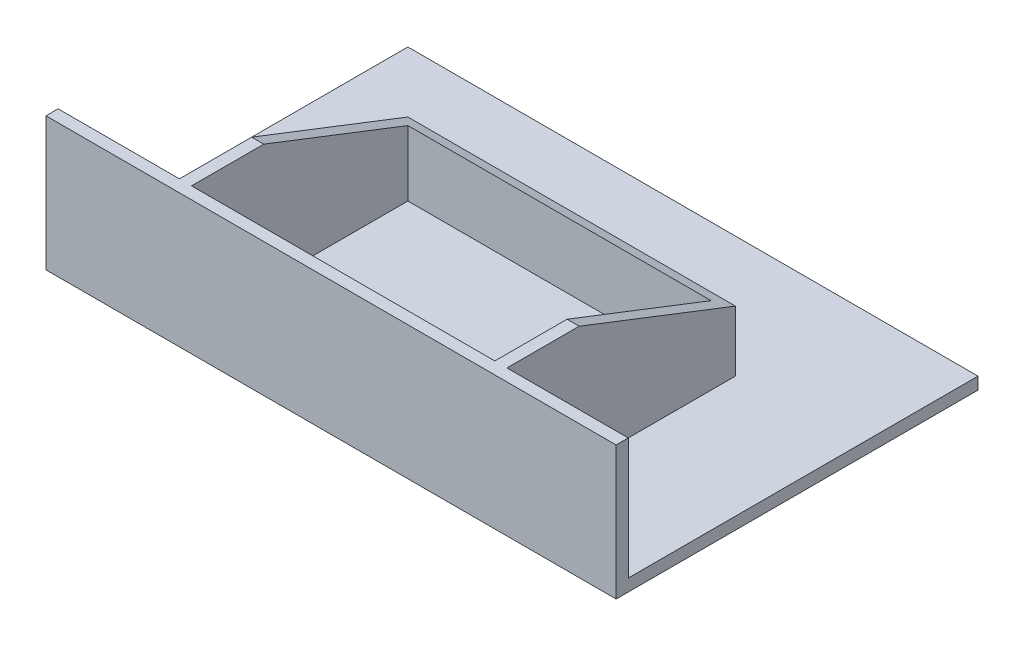
from build123d import *

# Parameters (mm, degrees)
CROQUIS1_R              = 2.1
SALIENTE_EXTRUIR1_DEPTH = 27
CROQUIS2_W              = 50
CROQUIS2_H              = 35.661242199
CORTAR_EXTRUIR1_DEPTH   = 20
CROQUIS3_W              = 94
CROQUIS3_H              = 22
SALIENTE_EXTRUIR2_DEPTH = 2
CROQUIS4_W              = 94
CROQUIS4_H              = 57.661242199
SALIENTE_EXTRUIR3_DEPTH = 2


with BuildPart() as part:
    # Croquis1 → Saliente-Extruir1 (new body, symmetric)
    with BuildSketch(Plane(origin=(0, 0, 0), x_dir=(0, 0, -1), z_dir=(1, 0, 0))):
        Polygon((0, 0), (0, 20), (11.90751736, 20), (37.661242199, 10), (37.661242199, 0), align=None)
        with Locations((4, 5)):
            Circle(CROQUIS1_R, mode=Mode.SUBTRACT)
    extrude(amount=SALIENTE_EXTRUIR1_DEPTH, both=True)

    # Croquis2 → Cortar-Extruir1 (cut)
    with BuildSketch(Plane(origin=(0, 20, 0), x_dir=(1, 0, 0), z_dir=(0, 1, 0))):
        with Locations((0, 17.8306211)):
            Rectangle(CROQUIS2_W, CROQUIS2_H)
    extrude(amount=-CORTAR_EXTRUIR1_DEPTH, mode=Mode.SUBTRACT)

    # Croquis3 → Saliente-Extruir2 (add)
    with BuildSketch(Plane.XY):
        with Locations((0, 9)):
            Rectangle(CROQUIS3_W, CROQUIS3_H)
    extrude(amount=SALIENTE_EXTRUIR2_DEPTH)

    # Croquis4 → Saliente-Extruir3 (add)
    with BuildSketch(Plane.XZ):
        with Locations((0, -28.8306211)):
            Rectangle(CROQUIS4_W, CROQUIS4_H)
    extrude(amount=SALIENTE_EXTRUIR3_DEPTH)


solid = part.part
